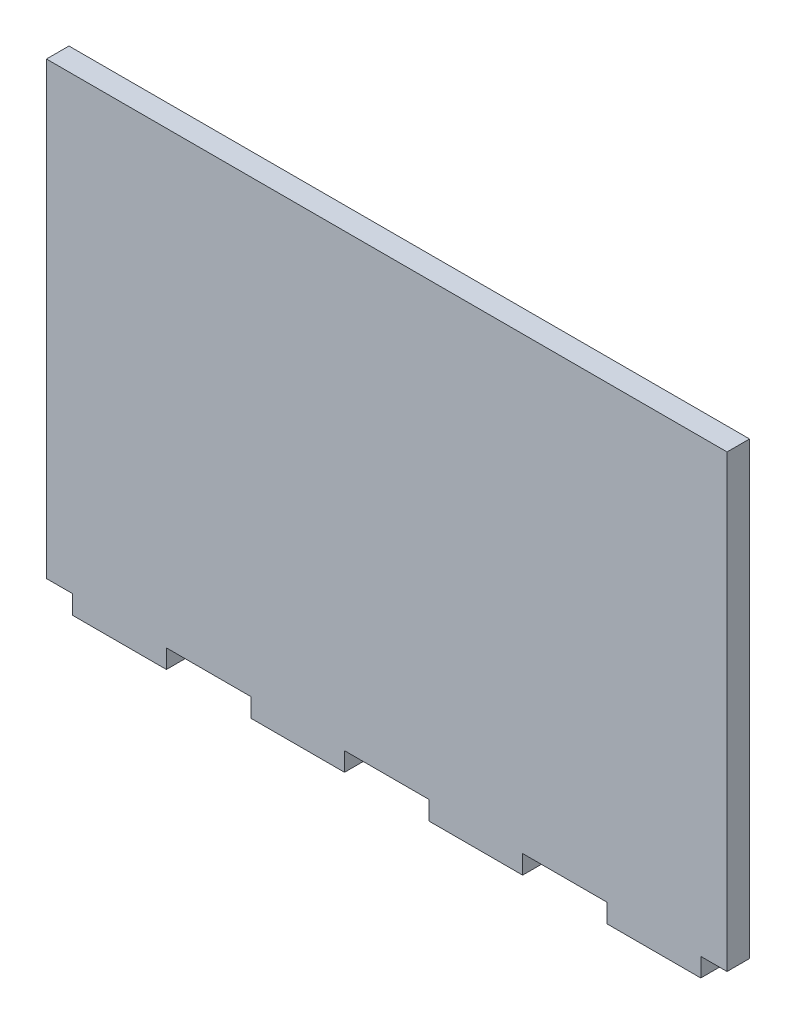
from build123d import *

# Parameters (mm, degrees)
ESQUISSE1_W        = 181.5
ESQUISSE1_H        = 120
ESQUISSE1_W_2      = 24.98
ESQUISSE1_H_2      = 5
BOSS_EXTRU_1_DEPTH = 6


with BuildPart() as part:
    # Esquisse1 → Boss.-Extru.1 (new body)
    with BuildSketch(Plane.XY):
        with Locations((-26.290054673, 38.2674)):
            Rectangle(ESQUISSE1_W, ESQUISSE1_H)
        with Locations((-97.540054673, -24.2326)):
            Rectangle(ESQUISSE1_W_2, ESQUISSE1_H_2)
        with Locations((-50.040054673, -24.2326)):
            Rectangle(ESQUISSE1_W_2, ESQUISSE1_H_2)
        with Locations((-2.540054673, -24.2326)):
            Rectangle(ESQUISSE1_W_2, ESQUISSE1_H_2)
        with Locations((44.959945327, -24.2326)):
            Rectangle(ESQUISSE1_W_2, ESQUISSE1_H_2)
    extrude(amount=BOSS_EXTRU_1_DEPTH)


solid = part.part
